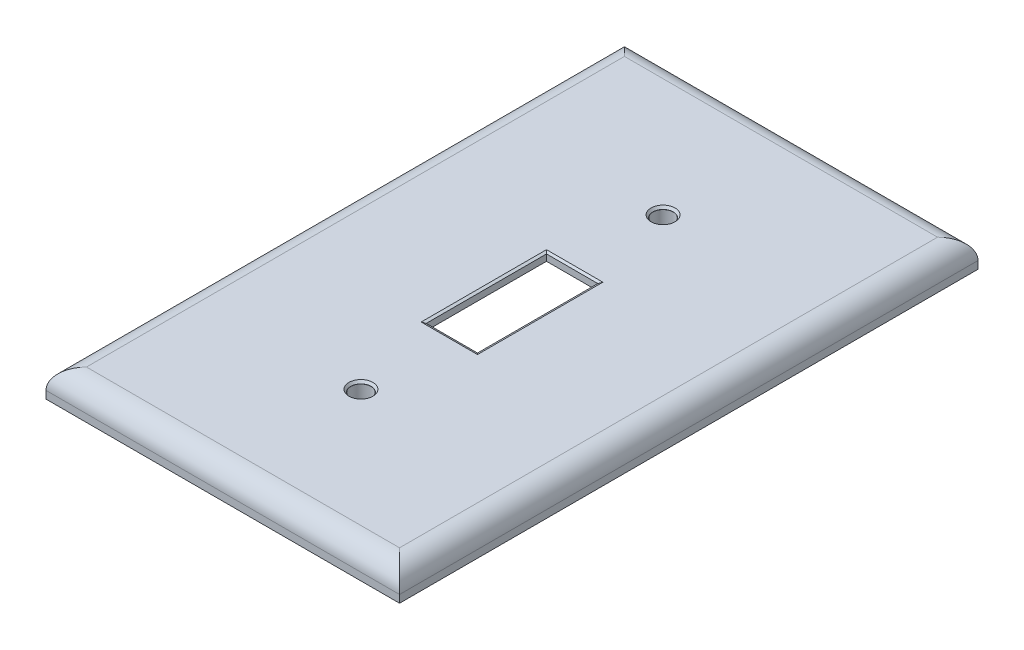
from build123d import *

# Parameters (mm, degrees)
SKETCH1_W            = 69.94
SKETCH1_H            = 114.43
BOSS_EXTRUDE1_DEPTH  = 5.5
FILLET1_R            = 4
SKETCH5_W            = 67.57
SKETCH5_H            = 112.06
CUT_EXTRUDE1_DEPTH   = 6
FILLET4_R            = 2.5
BOSS_EXTRUDE8_START  = -3
BOSS_EXTRUDE8_DEPTH  = 112.5
BOSS_EXTRUDE10_DEPTH = 68
SKETCH17_R           = 2.5
BOSS_EXTRUDE11_DEPTH = 4
SKETCH13_R           = 1.99
SKETCH13_W           = 10.15
SKETCH13_H           = 23.8
CUT_EXTRUDE2_DEPTH   = 10
SKETCH16_R           = 3.075
CUT_EXTRUDE3_DEPTH   = 1.5
CUT_EXTRUDE3_TAPER   = 35
CHAMFER1_SIZE        = 0.5
CHAMFER1_SIZE2       = 0.233153829


with BuildPart() as part:
    # Sketch1 → Boss-Extrude1 (new body)
    with BuildSketch(Plane(origin=(0, 0, 0), x_dir=(1, 0, 0), z_dir=(0, 1, 0))):
        Rectangle(SKETCH1_W, SKETCH1_H)
    extrude(amount=BOSS_EXTRUDE1_DEPTH)

    # Fillet1
    fillet1_edges = [part.edges().sort_by_distance(p)[0] for p in [
        (-34.97, 5.5, 0),
        (0, 5.5, 57.215),
        (34.97, 5.5, 0),
        (0, 5.5, -57.215),
    ]]
    fillet(fillet1_edges, radius=FILLET1_R)

    # Sketch5 → Cut-Extrude1 (cut)
    with BuildSketch(Plane(origin=(0, -2, 0), x_dir=(1, 0, 0), z_dir=(0, 1, 0))):
        Rectangle(SKETCH5_W, SKETCH5_H)
    extrude(amount=CUT_EXTRUDE1_DEPTH, mode=Mode.SUBTRACT)

    # Fillet4
    fillet4_edges = [part.edges().sort_by_distance(p)[0] for p in [
        (33.785, 4, 0),
        (0, 4, -56.03),
        (-33.785, 4, 0),
        (0, 4, 56.03),
    ]]
    fillet(fillet4_edges, radius=FILLET4_R)

    # Sketch12 → Boss-Extrude8 (add)
    with BuildSketch(Plane(origin=(0, 0, -59.215), x_dir=(-1, 0, 0), z_dir=(0, 0, -1)).offset(BOSS_EXTRUDE8_START)):
        with BuildLine():
            Line((21.685232417, 4), (17.815304419, 4))
            ThreePointArc((17.815304419, 4), (19.750268418, 2.50587975), (21.685232417, 4))
        make_face()
        with BuildLine():
            Line((-21.685232417, 4), (-17.815304419, 4))
            ThreePointArc((-17.815304419, 4), (-19.750268418, 2.50587975), (-21.685232417, 4))
        make_face()
    extrude(amount=-BOSS_EXTRUDE8_DEPTH)

    # Sketch15 → Boss-Extrude10 (add)
    with BuildSketch(Plane(origin=(33.97, 0, 0), x_dir=(0, 0, -1), z_dir=(1, 0, 0))):
        with BuildLine():
            Line((-31.885, 3.965022027), (-27.885, 3.965022027))
            ThreePointArc((-27.885, 3.965022027), (-29.885, 1.965022027), (-31.885, 3.965022027))
        make_face()
        with BuildLine():
            Line((31.885, 3.965022027), (27.885, 3.965022027))
            ThreePointArc((27.885, 3.965022027), (29.885, 1.965022027), (31.885, 3.965022027))
        make_face()
    extrude(amount=-BOSS_EXTRUDE10_DEPTH)

    # Sketch17 → Boss-Extrude11 (add)
    with BuildSketch(Plane(origin=(0, 4, 0), x_dir=(-1, 0, 0), z_dir=(0, -1, 0))):
        with Locations(Location((0, -29.885, 0), (0, 0, 90))):  # turned: the seam where the file's is
            Circle(SKETCH17_R)
        with Locations(Location((0, 29.885, 0), (0, 0, 270))):  # turned: the seam where the file's is
            Circle(SKETCH17_R)
    extrude(amount=BOSS_EXTRUDE11_DEPTH)

    # Sketch13 → Cut-Extrude2 (cut)
    with BuildSketch(Plane(origin=(0, 0, 0), x_dir=(1, 0, 0), z_dir=(0, 1, 0))):
        with Locations(Location((0, 29.885, 0), (0, 0, 90))):  # turned: the seam where the file's is
            Circle(SKETCH13_R)
        with Locations(Location((0, -29.885, 0), (0, 0, 90))):  # turned: the seam where the file's is
            Circle(SKETCH13_R)
        Rectangle(SKETCH13_W, SKETCH13_H)
    extrude(amount=CUT_EXTRUDE2_DEPTH, mode=Mode.SUBTRACT)

    # Sketch16 → Cut-Extrude3 (cut)
    with BuildSketch(Plane(origin=(0, 6.5, 0), x_dir=(1, 0, 0), z_dir=(0, 1, 0))):
        with Locations((0, 29.885)):
            Circle(SKETCH16_R)
        with Locations((0, -29.885)):
            Circle(SKETCH16_R)
    extrude(amount=-CUT_EXTRUDE3_DEPTH, taper=CUT_EXTRUDE3_TAPER, mode=Mode.SUBTRACT)

    # Chamfer1
    chamfer1_edges = [part.edges().sort_by_distance(p)[0] for p in [
        (0, 5.5, -11.9),
        (5.075, 5.5, 0),
        (0, 5.5, 11.9),
        (-5.075, 5.5, 0),
    ]]
    chamfer1_side = [part.faces().sort_by_distance(p)[0] for p in [
        (-29.738581773, 5.5, 0),
    ]]
    chamfer(chamfer1_edges, length=CHAMFER1_SIZE, length2=CHAMFER1_SIZE2, reference=chamfer1_side[0])


solid = part.part
